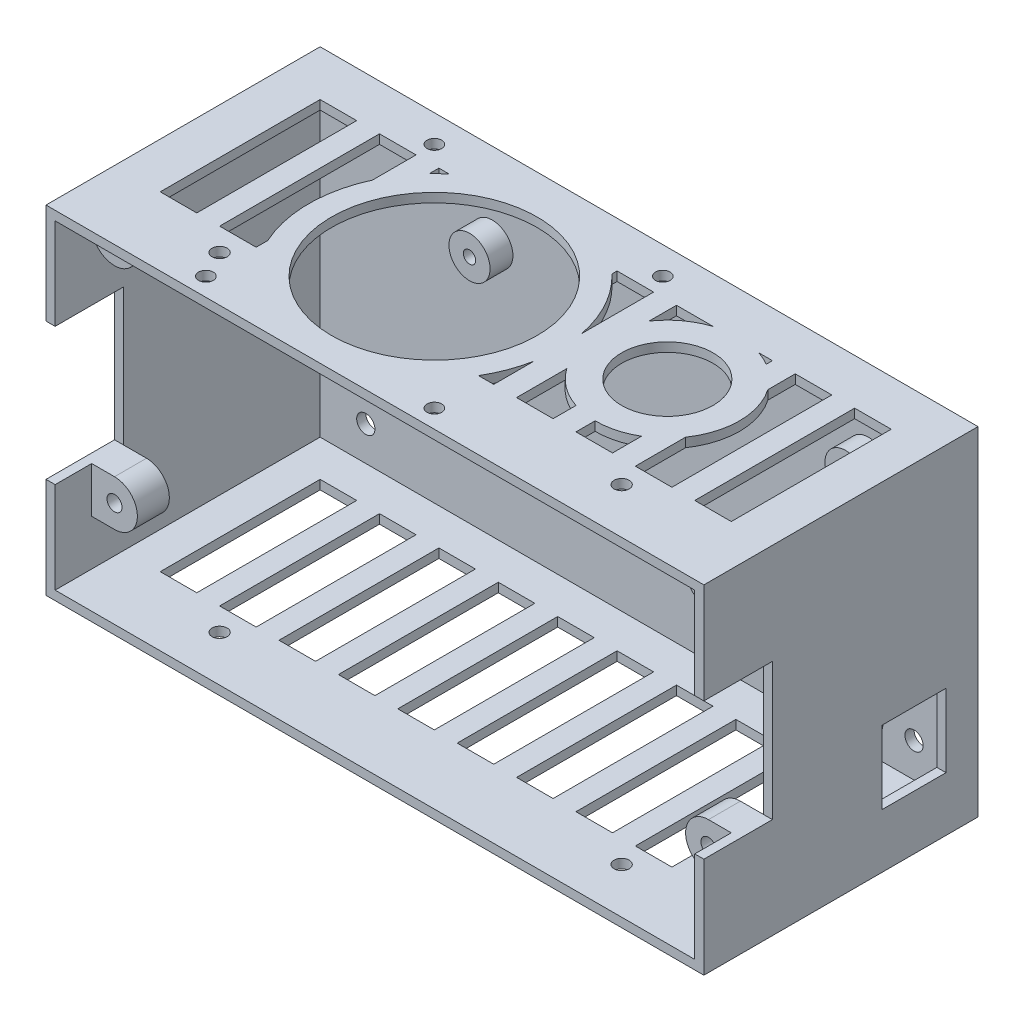
from build123d import *

# Parameters (mm, degrees)
ESBO_O1_W                  = 144
ESBO_O1_H                  = 74
ESBO_O1_W_2                = 140
ESBO_O1_H_2                = 70
RESSALTO_EXTRUS_O1_DEPTH   = 60
ESBO_O2_W                  = 144
ESBO_O2_H                  = 74
ESBO_O2_R                  = 2
RESSALTO_EXTRUS_O2_DEPTH   = 2
ESBO_O3_W                  = 14
ESBO_O3_H                  = 16
USB_FONTE_DEPTH            = 10
ESBO_O6_R                  = 1.65
ESBO_O6_W                  = 8
ESBO_O6_H                  = 35
SAIDA_DE_AR_DEPTH          = 1
SAIDA_DE_AR_DEPTH_BACK     = 75
ESBO_O7_W                  = 15
ESBO_O7_H                  = 30
DISPLAY_DEPTH              = 145
ESBO_O8_R                  = 4.5
ESBO_O8_R_2                = 1.35
RESSALTO_EXTRUS_O3_DEPTH   = 5
ESBO_O8_3_R                = 1.35
CORTE_EXTRUS_O4_DEPTH      = 3
ESBO_O9_R                  = 3
CORTE_EXTRUS_O5_DEPTH      = 2
CORTE_EXTRUS_O5_DEPTH_BACK = 10
RESSALTO_EXTRUS_O4_START   = -8
ESBO_O11_R                 = 1.65
RESSALTO_EXTRUS_O4_DEPTH   = 7
CORTE_EXTRUS_O6_DEPTH      = 3
ESBO_O13_R                 = 15.811388301
ESBO_O13_R_2               = 10
RESSALTO_EXTRUS_O5_DEPTH   = 2
ESBO_O13_3_R               = 10
CORTE_EXTRUS_O7_DEPTH      = 10
ESBO_O15_R                 = 22.5
ESBO_O15_R_2               = 1.6
CORTE_EXTRUS_O9_DEPTH      = 10
ESBO_O15_3_R               = 27.5
ESBO_O15_3_R_2             = 22.5
RESSALTO_EXTRUS_O6_DEPTH   = 2


with BuildPart() as part:
    # Esboço1 → Ressalto-extrusão1 (new body)
    with BuildSketch(Plane.XY):
        Rectangle(ESBO_O1_W, ESBO_O1_H)
        Rectangle(ESBO_O1_W_2, ESBO_O1_H_2, mode=Mode.SUBTRACT)
    extrude(amount=RESSALTO_EXTRUS_O1_DEPTH)

    # Esboço2 → Ressalto-extrusão2 (add)
    with BuildSketch(Plane(origin=(0, 0, 0), x_dir=(-1, 0, 0), z_dir=(0, 0, -1))):
        Rectangle(ESBO_O2_W, ESBO_O2_H)
        with Locations((-60, -27.5)):
            Circle(ESBO_O2_R, mode=Mode.SUBTRACT)
        with Locations((60, -27.5)):
            Circle(ESBO_O2_R, mode=Mode.SUBTRACT)
        with Locations((60, 27.5)):
            Circle(ESBO_O2_R, mode=Mode.SUBTRACT)
        with Locations((-60, 27.5)):
            Circle(ESBO_O2_R, mode=Mode.SUBTRACT)
    extrude(amount=-RESSALTO_EXTRUS_O2_DEPTH)

    # Esboço3 → USB _ fonte (cut)
    with BuildSketch(Plane(origin=(72, 0, 0), x_dir=(0, 0, -1), z_dir=(1, 0, 0))):
        with Locations((-14, -17.1)):
            Rectangle(ESBO_O3_W, ESBO_O3_H)
    extrude(amount=-USB_FONTE_DEPTH, mode=Mode.SUBTRACT)

    # Esboço6 → saida de ar (cut, two sides)
    with BuildSketch(Plane.XZ.offset(37)) as saida_de_ar_sk:
        with Locations((-44, 50)):
            Circle(ESBO_O6_R)
        with Locations((44, 50)):
            Circle(ESBO_O6_R)
        with Locations((-58, 27.5)):
            Rectangle(ESBO_O6_W, ESBO_O6_H)
        with Locations((-45, 27.5)):
            Rectangle(ESBO_O6_W, ESBO_O6_H)
        with Locations((-32, 27.5)):
            Rectangle(ESBO_O6_W, ESBO_O6_H)
        with Locations((-19, 27.5)):
            Rectangle(ESBO_O6_W, ESBO_O6_H)
        with Locations((-6, 27.5)):
            Rectangle(ESBO_O6_W, ESBO_O6_H)
        with Locations((7, 27.5)):
            Rectangle(ESBO_O6_W, ESBO_O6_H)
        with Locations((20, 27.5)):
            Rectangle(ESBO_O6_W, ESBO_O6_H)
        with Locations((33, 27.5)):
            Rectangle(ESBO_O6_W, ESBO_O6_H)
        with Locations((46, 27.5)):
            Rectangle(ESBO_O6_W, ESBO_O6_H)
        with Locations((59, 27.5)):
            Rectangle(ESBO_O6_W, ESBO_O6_H)
    extrude(amount=SAIDA_DE_AR_DEPTH, mode=Mode.SUBTRACT)
    extrude(saida_de_ar_sk.sketch, amount=-SAIDA_DE_AR_DEPTH_BACK, mode=Mode.SUBTRACT)

    # Esboço7 → display (cut, through all)
    with BuildSketch(Plane.ZY.offset(72)):
        with Locations((52.5, 0)):
            Rectangle(ESBO_O7_W, ESBO_O7_H)
    extrude(amount=-DISPLAY_DEPTH, mode=Mode.SUBTRACT)

    # Esboço8 → Ressalto-extrusão3 (add)
    with BuildSketch(Plane(origin=(0, 0, 2), x_dir=(-1, 0, 0), z_dir=(0, 0, -1))):
        with Locations((32.3, 20.5)):
            Circle(ESBO_O8_R)
        with Locations((32.3, 20.5)):
            Circle(ESBO_O8_R_2, mode=Mode.SUBTRACT)
        with Locations((-50, 20.5)):
            Circle(ESBO_O8_R)
        with Locations((-50, 20.5)):
            Circle(ESBO_O8_R_2, mode=Mode.SUBTRACT)
        with Locations((-48.7, -27.67)):
            Circle(ESBO_O8_R)
        with Locations((-48.7, -27.67)):
            Circle(ESBO_O8_R_2, mode=Mode.SUBTRACT)
    extrude(amount=-RESSALTO_EXTRUS_O3_DEPTH)

    # Esboço8<3> → Corte-extrusão4 (cut, through all)
    with BuildSketch(Plane(origin=(0, 0, 2), x_dir=(-1, 0, 0), z_dir=(0, 0, -1))):
        with Locations((-48.7, -27.67)):
            Circle(ESBO_O8_3_R)
        with Locations((32.3, 20.5)):
            Circle(ESBO_O8_3_R)
        with Locations((-50, 20.5)):
            Circle(ESBO_O8_3_R)
    extrude(amount=CORTE_EXTRUS_O4_DEPTH, mode=Mode.SUBTRACT)

    # Esboço9 → Corte-extrusão5 (cut, two sides)
    with BuildSketch(Plane.XY.offset(2)) as corte_extrus_o5_sk:
        with Locations((50, 20.5)):
            Circle(ESBO_O9_R)
        with Locations((48.7, -27.67)):
            Circle(ESBO_O9_R)
        with Locations((-32.3, 20.5)):
            Circle(ESBO_O9_R)
    extrude(amount=CORTE_EXTRUS_O5_DEPTH, mode=Mode.SUBTRACT)
    extrude(corte_extrus_o5_sk.sketch, amount=-CORTE_EXTRUS_O5_DEPTH_BACK, mode=Mode.SUBTRACT)

    # Esboço11 → Ressalto-extrusão4 (add)
    with BuildSketch(Plane.XY.offset(60).offset(RESSALTO_EXTRUS_O4_START)):
        with BuildLine():
            Line((70, -25), (65, -25))
            ThreePointArc((65, -25), (60, -20), (65, -15))
            Line((65, -15), (70, -15))
            Line((70, -15), (70, -25))
        make_face()
        with Locations((65, -20)):
            Circle(ESBO_O11_R, mode=Mode.SUBTRACT)
        with BuildLine():
            Line((70, 35), (65, 35))
            ThreePointArc((65, 35), (61.464466094, 26.464466094), (70, 30))
            Line((70, 30), (70, 35))
        make_face()
        with Locations((65, 30)):
            Circle(ESBO_O11_R, mode=Mode.SUBTRACT)
        with BuildLine():
            Line((-70, -25), (-70, -15))
            Line((-70, -15), (-65, -15))
            ThreePointArc((-65, -15), (-60, -20), (-65, -25))
            Line((-65, -25), (-70, -25))
        make_face()
        with Locations((-65, -20)):
            Circle(ESBO_O11_R, mode=Mode.SUBTRACT)
        with BuildLine():
            Line((-65, 35), (-70, 35))
            Line((-70, 35), (-70, 30))
            ThreePointArc((-70, 30), (-61.464466094, 26.464466094), (-65, 35))
        make_face()
        with Locations((-65, 30)):
            Circle(ESBO_O11_R, mode=Mode.SUBTRACT)
    extrude(amount=-RESSALTO_EXTRUS_O4_DEPTH)

    # Esboço12 → Corte-extrusão6 (cut)
    with BuildSketch(Plane(origin=(0, 0, 45), x_dir=(-1, 0, 0), z_dir=(0, 0, -1))):
        Polygon((-61.824573519, 30), (-63.41228676, 32.75), (-66.58771324, 32.75), (-68.175426481, 30), (-66.58771324, 27.25), (-63.41228676, 27.25), align=None)
        Polygon((61.824573519, 30), (63.41228676, 27.25), (66.58771324, 27.25), (68.175426481, 30), (66.58771324, 32.75), (63.41228676, 32.75), align=None)
        Polygon((-61.824573519, -20), (-63.41228676, -17.25), (-66.58771324, -17.25), (-68.175426481, -20), (-66.58771324, -22.75), (-63.41228676, -22.75), align=None)
        Polygon((61.824573519, -20), (63.41228676, -22.75), (66.58771324, -22.75), (68.175426481, -20), (66.58771324, -17.25), (63.41228676, -17.25), align=None)
    extrude(amount=-CORTE_EXTRUS_O6_DEPTH, mode=Mode.SUBTRACT)

    # Esboço13 → Ressalto-extrusão5 (add)
    with BuildSketch(Plane(origin=(0, 37, 0), x_dir=(1, 0, 0), z_dir=(0, 1, 0))):
        with Locations((29, -25)):
            Circle(ESBO_O13_R)
        with Locations((29, -25)):
            Circle(ESBO_O13_R_2, mode=Mode.SUBTRACT)
    extrude(amount=-RESSALTO_EXTRUS_O5_DEPTH)

    # Esboço13<3> → Corte-extrusão7 (cut)
    with BuildSketch(Plane(origin=(0, 37, 0), x_dir=(1, 0, 0), z_dir=(0, 1, 0))):
        with Locations((29, -25)):
            Circle(ESBO_O13_3_R)
    extrude(amount=-CORTE_EXTRUS_O7_DEPTH, mode=Mode.SUBTRACT)

    # Esboço15 → Corte-extrusão9 (cut)
    with BuildSketch(Plane(origin=(0, 37, 0), x_dir=(1, 0, 0), z_dir=(0, 1, 0))):
        with Locations((-16, -31)):
            Circle(ESBO_O15_R)
        with Locations((-41, -56)):
            Circle(ESBO_O15_R_2)
        with Locations((9, -56)):
            Circle(ESBO_O15_R_2)
        with Locations((-41, -6)):
            Circle(ESBO_O15_R_2)
        with Locations((9, -6)):
            Circle(ESBO_O15_R_2)
    extrude(amount=-CORTE_EXTRUS_O9_DEPTH, mode=Mode.SUBTRACT)

    # Esboço15<3> → Ressalto-extrusão6 (add)
    with BuildSketch(Plane(origin=(0, 37, 0), x_dir=(1, 0, 0), z_dir=(0, 1, 0))):
        with Locations((-16, -31)):
            Circle(ESBO_O15_3_R)
        with Locations((-16, -31)):
            Circle(ESBO_O15_3_R_2, mode=Mode.SUBTRACT)
    extrude(amount=-RESSALTO_EXTRUS_O6_DEPTH)


solid = part.part
